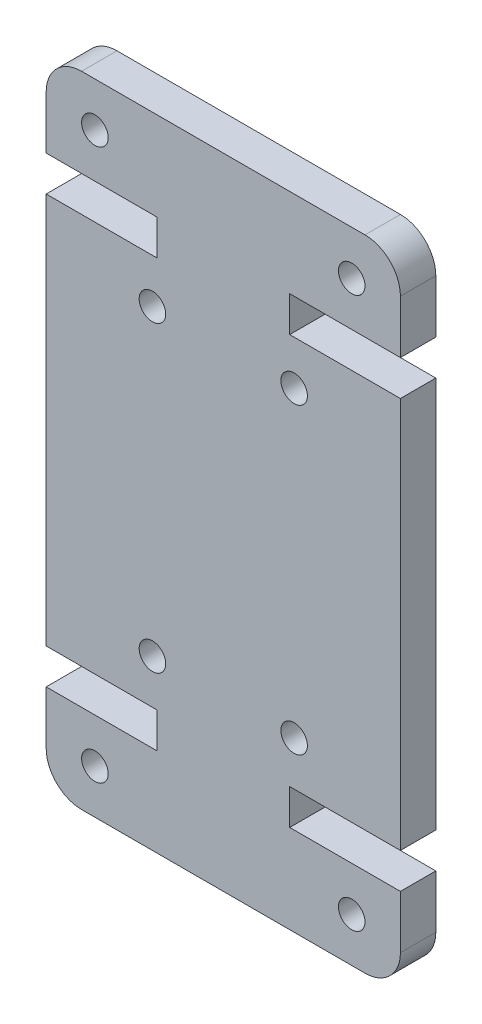
from build123d import *

# Parameters (mm, degrees)
MODEL_R             = 0.75
BOSS_EXTRUDE1_DEPTH = 2


with BuildPart() as part:
    # Model → Boss-Extrude1 (new body)
    with BuildSketch(Plane.XY):
        with BuildLine():
            Line((2, 36.1), (18, 36.1))
            ThreePointArc((18, 36.1), (19.414213562, 35.514213562), (20, 34.1))
            Line((20, 34.1), (20, 31.1))
            Line((20, 31.1), (13.75, 31.1))
            Line((13.75, 31.1), (13.75, 29.1))
            Line((13.75, 29.1), (20, 29.1))
            Line((20, 29.1), (20, 7))
            Line((20, 7), (13.75, 7))
            Line((13.75, 7), (13.75, 5))
            Line((13.75, 5), (20, 5))
            Line((20, 5), (20, 2))
            ThreePointArc((20, 2), (19.414213562, 0.585786438), (18, 0))
            Line((18, 0), (2, 0))
            ThreePointArc((2, 0), (0.585786438, 0.585786438), (0, 2))
            Line((0, 2), (0, 5))
            Line((0, 5), (6.25, 5))
            Line((6.25, 5), (6.25, 7))
            Line((6.25, 7), (0, 7))
            Line((0, 7), (0, 29.1))
            Line((0, 29.1), (6.25, 29.1))
            Line((6.25, 29.1), (6.25, 31.1))
            Line((6.25, 31.1), (0, 31.1))
            Line((0, 31.1), (0, 34.1))
            ThreePointArc((0, 34.1), (0.585786438, 35.514213562), (2, 36.1))
        make_face()
        with Locations((14, 26.6)):
            Circle(MODEL_R, mode=Mode.SUBTRACT)
        with Locations((6, 26.6)):
            Circle(MODEL_R, mode=Mode.SUBTRACT)
        with Locations((14, 9.5)):
            Circle(MODEL_R, mode=Mode.SUBTRACT)
        with Locations((6, 9.5)):
            Circle(MODEL_R, mode=Mode.SUBTRACT)
        with Locations((17.25, 2.5)):
            Circle(MODEL_R, mode=Mode.SUBTRACT)
        with Locations((2.75, 2.5)):
            Circle(MODEL_R, mode=Mode.SUBTRACT)
        with Locations((17.25, 33.6)):
            Circle(MODEL_R, mode=Mode.SUBTRACT)
        with Locations((2.75, 33.6)):
            Circle(MODEL_R, mode=Mode.SUBTRACT)
    extrude(amount=BOSS_EXTRUDE1_DEPTH)


solid = part.part
